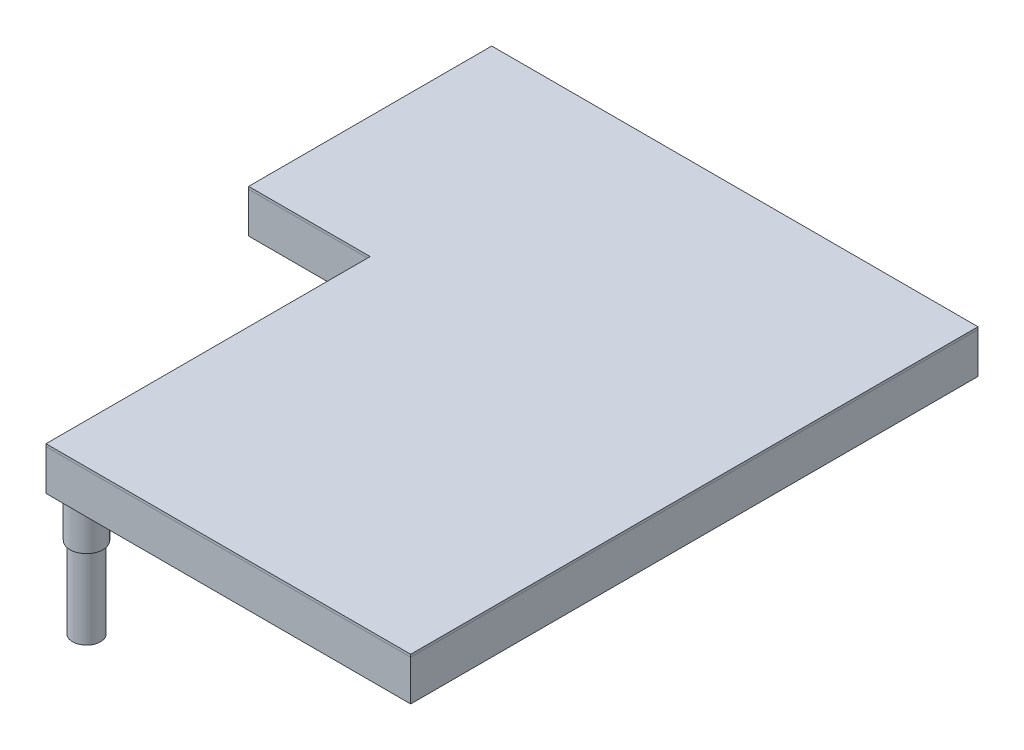
from build123d import *

# Parameters (mm, degrees)
BOSS_EXTRUDE1_DEPTH = 1.5875
BOSS_EXTRUDE2_DEPTH = 50.8
SKETCH3_R           = 17.4625
BOSS_EXTRUDE3_DEPTH = 152.4
SKETCH4_R           = 20.6375
SKETCH4_R_2         = 17.4625
BOSS_EXTRUDE4_DEPTH = 50.8


with BuildPart() as part:
    # Sketch1 → Boss-Extrude1 (new body, symmetric)
    with BuildSketch(Plane(origin=(0, 0, 0), x_dir=(1, 0, 0), z_dir=(0, 1, 0))):
        Polygon((0, 0), (0, 406.4), (-152.4, 406.4), (-152.4, 711.2), (457.2, 711.2), (457.2, 0), align=None)
    extrude(amount=BOSS_EXTRUDE1_DEPTH, both=True)


with BuildPart() as body_2:
    # Sketch2 → Boss-Extrude2 (new body)
    with BuildSketch(Plane.XZ.offset(1.5875)):
        Polygon((457.2, 0), (0, 0), (0, -406.4), (-152.4, -406.4), (-152.4, -711.2), (457.2, -711.2), align=None)
        Polygon((406.4, -50.8), (50.8, -50.8), (50.8, -457.2), (-101.6, -457.2), (-101.6, -660.4), (406.4, -660.4), align=None, mode=Mode.SUBTRACT)
    extrude(amount=BOSS_EXTRUDE2_DEPTH)

    # Sketch3 → Boss-Extrude3 (add)
    with BuildSketch(Plane.XZ.offset(52.3875)):
        with Locations(Location((25.4, -25.4, 0), (0, 0, 270))):  # turned: the seam where the file's is
            Circle(SKETCH3_R)
    extrude(amount=BOSS_EXTRUDE3_DEPTH)


with BuildPart() as body_3:
    # Sketch4 → Boss-Extrude4 (new body)
    with BuildSketch(Plane.XZ.offset(52.3875)):
        with Locations(Location((25.4, -25.4, 0), (0, 0, 270))):  # turned: the seam where the file's is
            Circle(SKETCH4_R)
        with Locations(Location((25.4, -25.4, 0), (0, 0, 270))):  # turned: the seam where the file's is
            Circle(SKETCH4_R_2, mode=Mode.SUBTRACT)
    extrude(amount=BOSS_EXTRUDE4_DEPTH)


solid = Compound([part.part, body_2.part, body_3.part])
